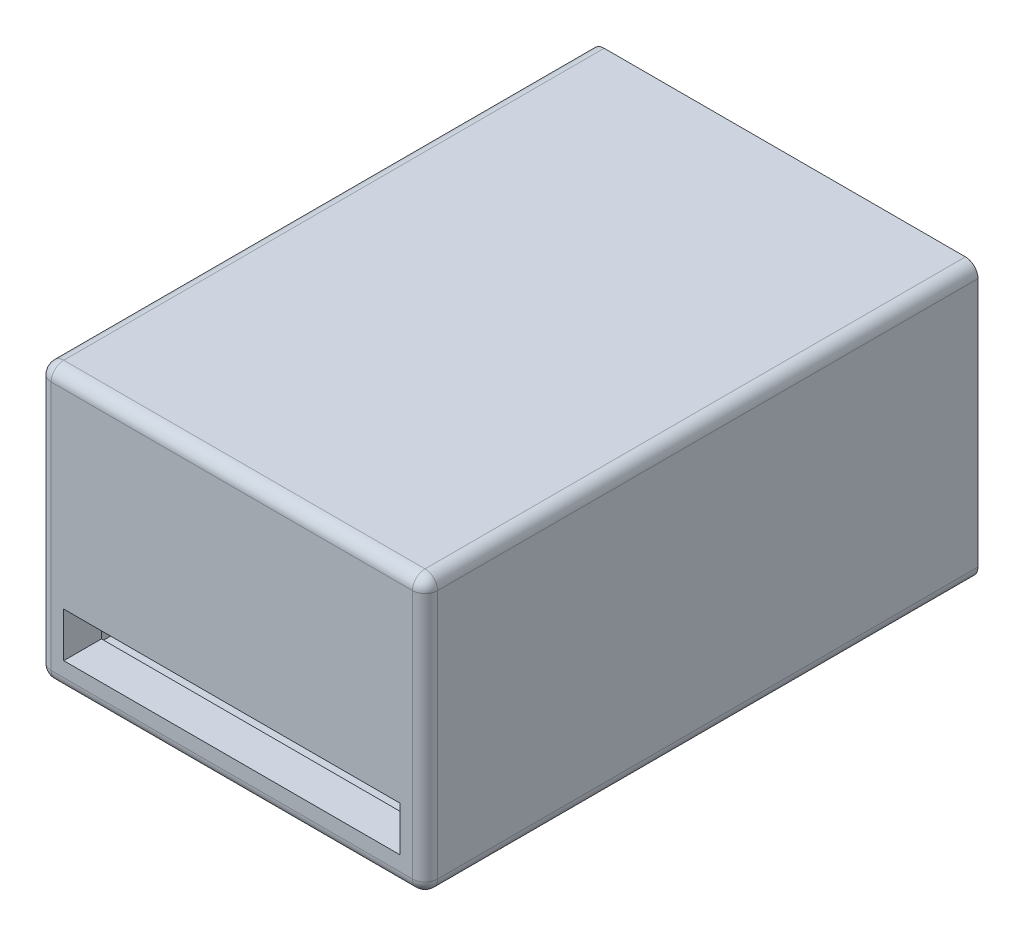
from build123d import *

# Parameters (mm, degrees)
ESQUISSE1_W             = 61.5
ESQUISSE1_H             = 43.75
BOSS_EXTRU_1_DEPTH      = 88
ENL_V_MAT_EXTRU_4_REACH = 90
ESQUISSE3_W             = 53.5
ESQUISSE3_H             = 7.118224843
ESQUISSE6_W             = 57.502648101
ESQUISSE6_H             = 39.75
ENL_V_MAT_EXTRU_5_DEPTH = 82
CONG_4_R                = 2
ESQUISSE7_R             = 1.5
BOSS_EXTRU_2_DEPTH      = 5.2
ESQUISSE8_R             = 1.5
BOSS_EXTRU_3_DEPTH      = 5.2


with BuildPart() as part:
    # Esquisse1 → Boss.-Extru.1 (new body)
    with BuildSketch(Plane.XY):
        with Locations((-0.850502513, 12.751256281)):
            Rectangle(ESQUISSE1_W, ESQUISSE1_H)
    extrude(amount=BOSS_EXTRU_1_DEPTH)

    # Esquisse3 → Enlèv. mat.-Extru.4 (cut, up to next)
    with BuildSketch(Plane.XY.offset(88), mode=Mode.PRIVATE) as enl_v_mat_extru_4_sk1:
        with Locations((-0.850502513, -1.222513082)):
            Rectangle(ESQUISSE3_W, ESQUISSE3_H)
    enl_v_mat_extru_4_tool1 = extrude(enl_v_mat_extru_4_sk1.sketch, amount=-ENL_V_MAT_EXTRU_4_REACH, mode=Mode.PRIVATE) & part.part
    add(enl_v_mat_extru_4_tool1.solids().sort_by_distance((-0.850503, -1.222513, 88))[0], mode=Mode.SUBTRACT)

    # Esquisse6 → Enlèv. mat.-Extru.5 (cut)
    with BuildSketch(Plane(origin=(0, 0, 0), x_dir=(-1, 0, 0), z_dir=(0, 0, -1))):
        with Locations((0.849178462, 12.751256281)):
            Rectangle(ESQUISSE6_W, ESQUISSE6_H)
    extrude(amount=-ENL_V_MAT_EXTRU_5_DEPTH, mode=Mode.SUBTRACT)

    # Congé4
    cong_4_edges = [part.edges().sort_by_distance(p)[0] for p in [
        (29.899497487, 12.751256281, 88),
        (-0.850502513, 34.626256281, 88),
        (-31.600502513, 12.751256281, 88),
        (-31.600502513, 34.626256281, 44),
        (29.899497487, 34.626256281, 44),
        (29.899497487, -9.123743719, 44),
        (-31.600502513, -9.123743719, 44),
        (-0.850502513, -9.123743719, 88),
    ]]
    fillet(cong_4_edges, radius=CONG_4_R)

    # Esquisse7 → Boss.-Extru.2 (add)
    with BuildSketch(Plane(origin=(0, -7.123743719, 0), x_dir=(1, 0, 0), z_dir=(0, 1, 0))):
        with Locations((18.002145588, -9.4)):
            Circle(ESQUISSE7_R)
    extrude(amount=BOSS_EXTRU_2_DEPTH)

    # Esquisse8 → Boss.-Extru.3 (add)
    with BuildSketch(Plane(origin=(0, -7.123743719, 0), x_dir=(1, 0, 0), z_dir=(0, 1, 0))):
        with Locations((-9.850502513, -9.5)):
            Circle(ESQUISSE8_R)
    extrude(amount=BOSS_EXTRU_3_DEPTH)


solid = part.part
